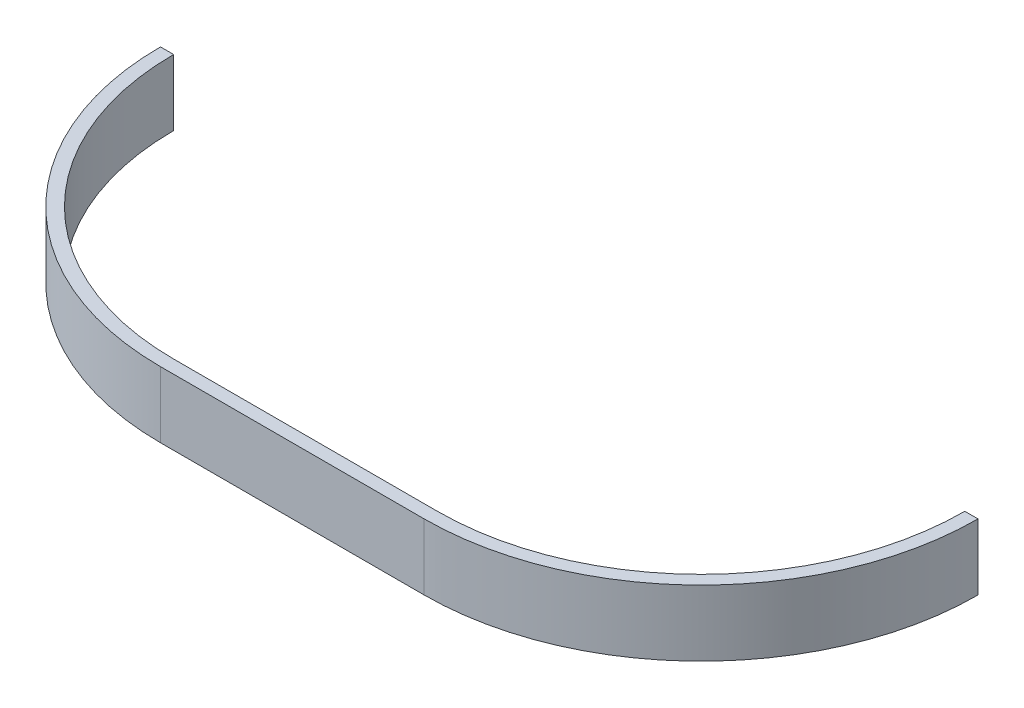
from build123d import *

# Parameters (mm, degrees)
EXTRUDE_1_DEPTH = 20


with BuildPart() as part:
    # 草图1 → 凸台-拉伸1 (new body)
    with BuildSketch(Plane(origin=(0, 0, 0), x_dir=(1, 0, 0), z_dir=(0, 1, 0))):
        with BuildLine():
            Line((120, 0), (124, 0))
            ThreePointArc((124, 0), (99.39696962, -59.39696962), (40, -84))
            Line((40, -84), (-40, -84))
            ThreePointArc((-40, -84), (-99.39696962, -59.39696962), (-124, 0))
            Line((-124, 0), (-120, 0))
            ThreePointArc((-120, 0), (-96.568542495, -56.568542495), (-40, -80))
            Line((-40, -80), (40, -80))
            ThreePointArc((40, -80), (96.568542495, -56.568542495), (120, 0))
        make_face()
    extrude(amount=EXTRUDE_1_DEPTH)


solid = part.part
